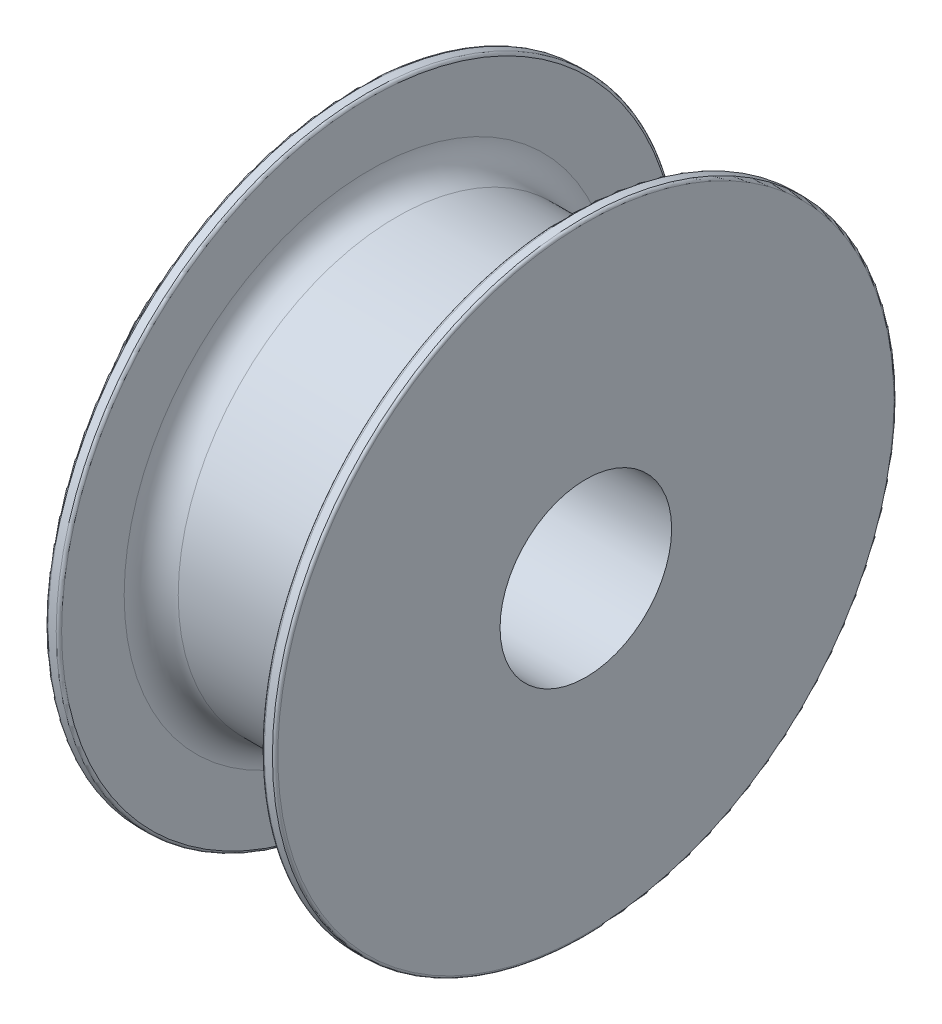
from build123d import *

# Parameters (mm, degrees)
SKETCH1_R           = 16.170155876
SKETCH1_R_2         = 6.35
BOSS_EXTRUDE1_DEPTH = 15
SKETCH2_R           = 23
SKETCH2_R_2         = 6.35
BOSS_EXTRUDE2_DEPTH = 1
SKETCH3_R           = 23
SKETCH3_R_2         = 6.35
BOSS_EXTRUDE3_DEPTH = 1
FILLET1_R           = 2
FILLET2_R           = 0.2
SKETCH4_R           = 12.5
SKETCH4_R_2         = 6.35
BOSS_EXTRUDE4_DEPTH = 7.5
SKETCH5_R           = 3.175
CUT_EXTRUDE1_DEPTH  = 17.5
FILLET3_R           = 0.2


with BuildPart() as part:
    # Sketch1 → Boss-Extrude1 (new body)
    with BuildSketch(Plane(origin=(0, 0, 0), x_dir=(0, 0, -1), z_dir=(1, 0, 0))):
        Circle(SKETCH1_R)
        Circle(SKETCH1_R_2, mode=Mode.SUBTRACT)
    extrude(amount=BOSS_EXTRUDE1_DEPTH)

    # Sketch2 → Boss-Extrude2 (add)
    with BuildSketch(Plane(origin=(15, 0, 0), x_dir=(0, 0, -1), z_dir=(1, 0, 0))):
        Circle(SKETCH2_R)
        Circle(SKETCH2_R_2, mode=Mode.SUBTRACT)
    extrude(amount=BOSS_EXTRUDE2_DEPTH)

    # Sketch3 → Boss-Extrude3 (add)
    with BuildSketch(Plane.ZY):
        Circle(SKETCH3_R)
        Circle(SKETCH3_R_2, mode=Mode.SUBTRACT)
    extrude(amount=BOSS_EXTRUDE3_DEPTH)

    # Fillet1
    fillet1_edges = [part.edges().sort_by_distance(p)[0] for p in [
        (0, 0, 16.170155876),
        (15, 0, 16.170155876),
    ]]
    fillet(fillet1_edges, radius=FILLET1_R)

    # Fillet2
    fillet2_edges = [part.edges().sort_by_distance(p)[0] for p in [
        (15, 0, 23),
        (-1, 0, -23),
        (0, 0, -23),
        (16, 0, 23),
    ]]
    fillet(fillet2_edges, radius=FILLET2_R)

    # Sketch4 → Boss-Extrude4 (add)
    with BuildSketch(Plane.ZY.offset(1)):
        Circle(SKETCH4_R)
        Circle(SKETCH4_R_2, mode=Mode.SUBTRACT)
    extrude(amount=BOSS_EXTRUDE4_DEPTH)

    # Sketch5 → Cut-Extrude1 (cut)
    with BuildSketch(Plane.XY):
        with Locations((-4.432338259, 0)):
            Circle(SKETCH5_R)
    extrude(amount=-CUT_EXTRUDE1_DEPTH, mode=Mode.SUBTRACT)

    # Fillet3
    fillet3_edges = [part.edges().sort_by_distance(p)[0] for p in [
        (-8.5, 0, -12.5),
    ]]
    fillet(fillet3_edges, radius=FILLET3_R)


solid = part.part
